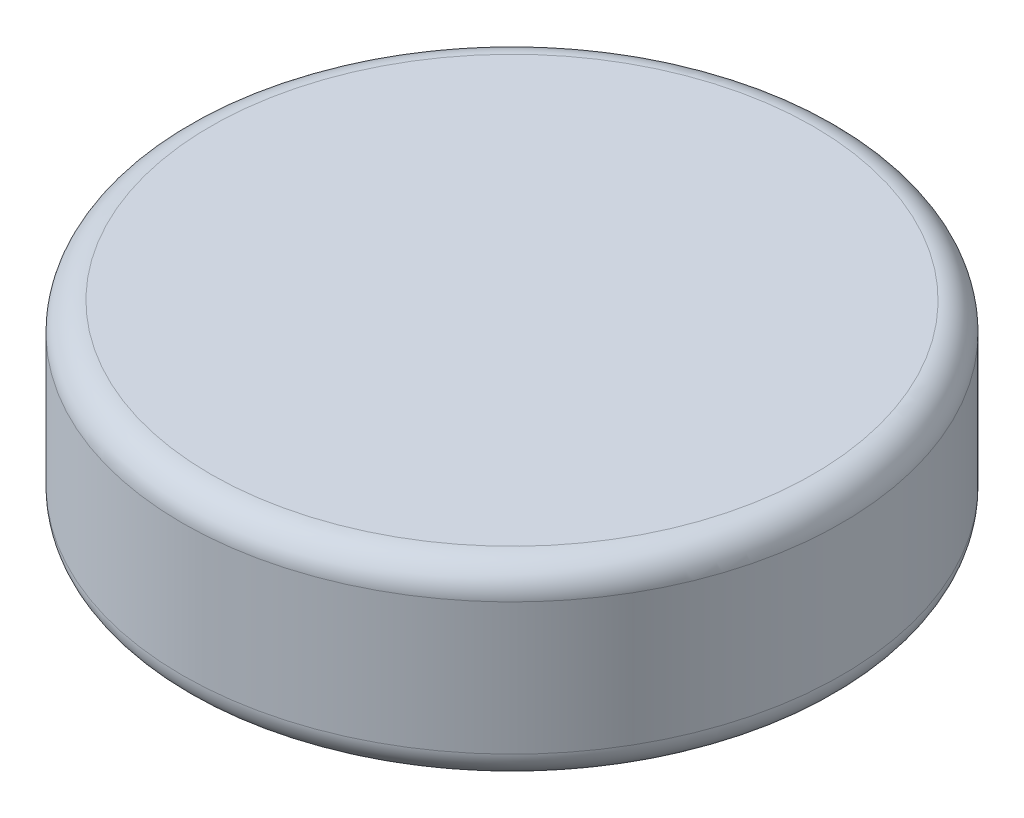
from build123d import *

# Parameters (mm, degrees)
SKETCH1_R           = 3.5
BOSS_EXTRUDE1_DEPTH = 2
FILLET1_R           = 0.3


with BuildPart() as part:
    # Sketch1 → Boss-Extrude1 (new body)
    with BuildSketch(Plane(origin=(0, 0, 0), x_dir=(1, 0, 0), z_dir=(0, 1, 0))):
        Circle(SKETCH1_R)
    extrude(amount=BOSS_EXTRUDE1_DEPTH)

    # Fillet1
    fillet1_edges = [part.edges().sort_by_distance(p)[0] for p in [
        (-3.5, 0, 0),
        (-3.5, 2, 0),
    ]]
    fillet(fillet1_edges, radius=FILLET1_R)


solid = part.part
